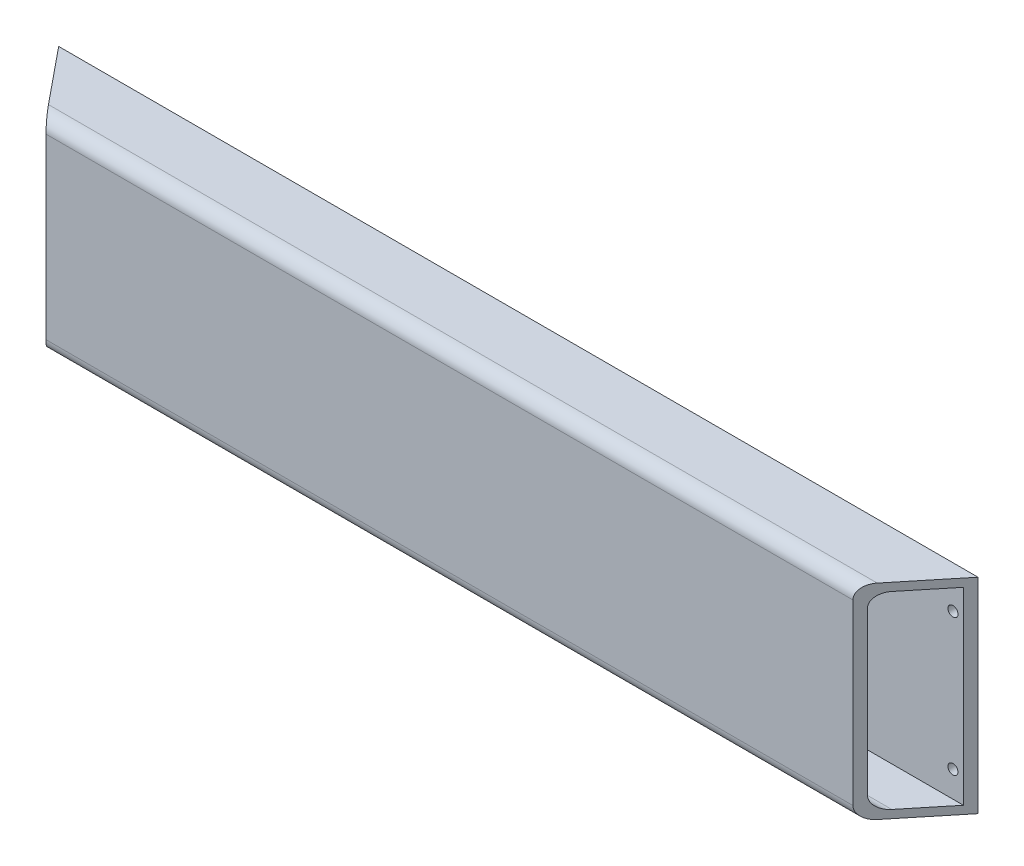
from build123d import *

# Parameters (mm, degrees)
SKETCH1_W           = 686.81
SKETCH1_H           = 153
BOSS_EXTRUDE1_DEPTH = 51.46
CUT_EXTRUDE1_DEPTH  = 153
SHELL1_T            = -6
SKETCH3_R           = 3.75
CUT_EXTRUDE2_DEPTH  = 6
FILLET1_R           = 10


with BuildPart() as part:
    # Sketch1 → Boss-Extrude1 (new body)
    with BuildSketch(Plane.XY):
        with Locations((343.405, 76.5)):
            Rectangle(SKETCH1_W, SKETCH1_H)
    extrude(amount=BOSS_EXTRUDE1_DEPTH)

    # Sketch2 → Cut-Extrude1 (cut)
    with BuildSketch(Plane.XZ):
        Polygon((0, 0), (42, 51.46), (-52.578690856, 191.351676445), (-175.691026148, 25.73), align=None)
        Polygon((686.81, 0), (644.81, 51.46), (843.619472118, 127.98285715), align=None)
    extrude(amount=-CUT_EXTRUDE1_DEPTH, mode=Mode.SUBTRACT)

    # Shell1
    shell1_openings = [part.faces().sort_by_distance(p)[0] for p in [
        (21, 76.5, 25.73),
        (665.81, 76.5, 25.73),
    ]]
    offset(amount=SHELL1_T, openings=shell1_openings, kind=Kind.INTERSECTION)

    # Sketch3 → Cut-Extrude2 (cut)
    with BuildSketch(Plane.XY.offset(6)):
        with Locations((12.7, 25.4)):
            Circle(SKETCH3_R)
        with Locations((12.7, 127.6)):
            Circle(SKETCH3_R)
        with Locations((674.11, 25.4)):
            Circle(SKETCH3_R)
        with Locations((674.11, 127.6)):
            Circle(SKETCH3_R)
    extrude(amount=-CUT_EXTRUDE2_DEPTH, mode=Mode.SUBTRACT)

    # Fillet1
    fillet1_edges = [part.edges().sort_by_distance(p)[0] for p in [
        (343.405, 0, 51.46),
        (343.405, 153, 51.46),
        (343.405, 6, 45.46),
        (343.405, 147, 45.46),
    ]]
    fillet(fillet1_edges, radius=FILLET1_R)


solid = part.part
